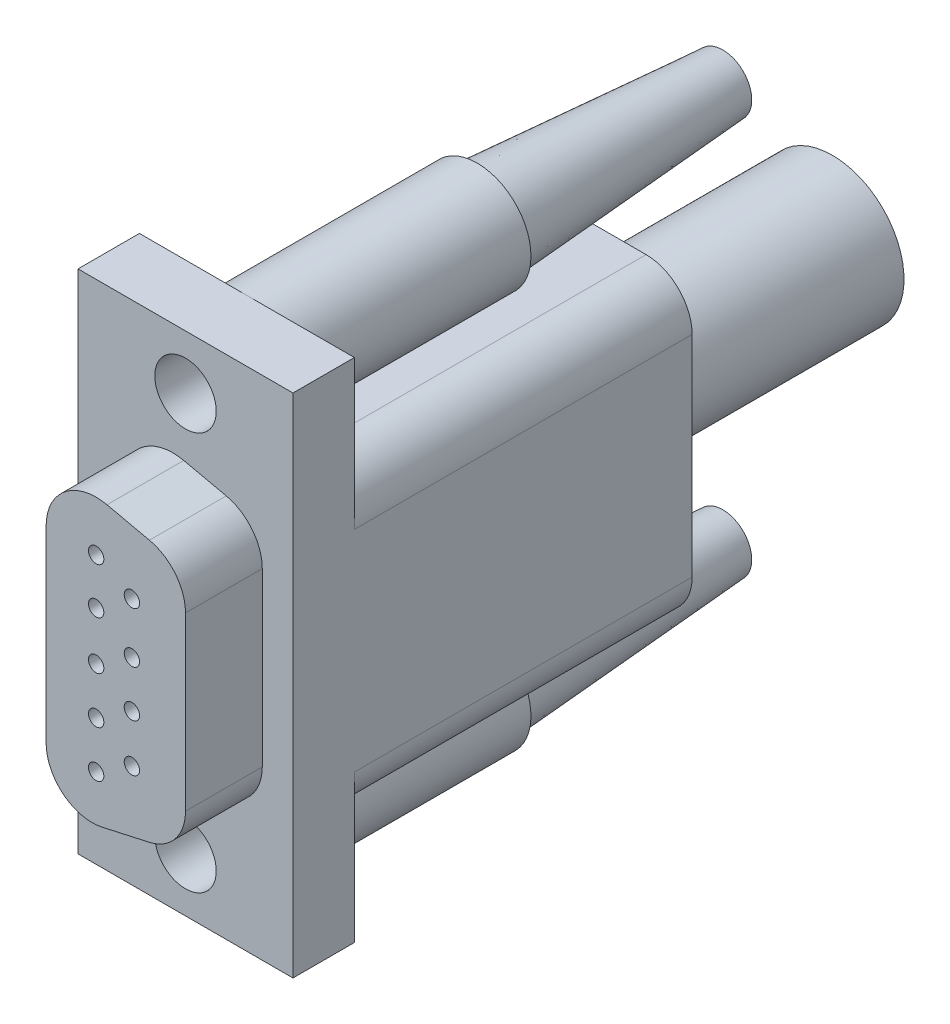
from build123d import *

# Parameters (mm, degrees)
EXTRUDE_1_DEPTH     = 5
SKETCH_2_5_R        = 0.5
CUT_EXTRUDE_1_DEPTH = 6
EXTRUDE_2_DEPTH     = 4
SKETCH_2_8_R        = 2
CUT_EXTRUDE_2_DEPTH = 4
SKETCH_3_R          = 3.5
EXTRUDE_3_DEPTH     = 15
EXTRUDE_4_DEPTH     = 22
SKETCH_5_R          = 3
EXTRUDE_5_DEPTH     = 16
EXTRUDE_5_TAPER     = 4
SKETCH_6_R          = 3
EXTRUDE_6_DEPTH     = 16
EXTRUDE_6_TAPER     = 4
SKETCH_7_R          = 4.663684065
EXTRUDE_7_DEPTH     = 16


with BuildPart() as part:
    # 草图2 → 凸台-拉伸1 (new body)
    with BuildSketch(Plane.XY):
        with BuildLine():
            Line((15.641000066, 15.243423767), (15.641000066, 3.009489297))
            ThreePointArc((15.641000066, 3.009489297), (16.763817885, 0.66936386), (19.291791439, 0.080928117))
            Line((19.291791439, 0.080928117), (22.370518946, 0.765089785))
            ThreePointArc((22.370518946, 0.765089785), (24.059853009, 1.816468785), (24.719727573, 3.693650965))
            Line((24.719727573, 3.693650965), (24.719727573, 14.880621327))
            ThreePointArc((24.719727573, 14.880621327), (24.059853009, 16.757803508), (22.370518946, 17.809182508))
            Line((22.370518946, 17.809182508), (19.605498159, 18.423631571))
            ThreePointArc((19.605498159, 18.423631571), (16.860299842, 17.784632476), (15.641000066, 15.243423767))
        make_face()
    extrude(amount=EXTRUDE_1_DEPTH)

    # 草图2<5> → 切除-拉伸1 (cut)
    with BuildSketch(Plane.XY):
        with Locations((18.898785314, 15.243423767)):
            Circle(SKETCH_2_5_R)
        with Locations((18.898785314, 12.243423767)):
            Circle(SKETCH_2_5_R)
        with Locations((18.898785314, 9.096563263)):
            Circle(SKETCH_2_5_R)
        with Locations((18.898785314, 6.048083228)):
            Circle(SKETCH_2_5_R)
        with Locations((18.898785314, 3.009489297)):
            Circle(SKETCH_2_5_R)
        with Locations((21.228436708, 13.929259558)):
            Circle(SKETCH_2_5_R)
        with Locations((21.228436708, 10.621115871)):
            Circle(SKETCH_2_5_R)
        with Locations((21.228436708, 7.588650825)):
            Circle(SKETCH_2_5_R)
        with Locations((21.228436708, 4.494923859)):
            Circle(SKETCH_2_5_R)
    extrude(amount=CUT_EXTRUDE_1_DEPTH, mode=Mode.SUBTRACT)

    # 草图2<6> → 凸台-拉伸2 (add)
    with BuildSketch(Plane.XY):
        Polygon((12.719727573, 9.287136146), (12.719727573, 25.787136146), (26.719727573, 25.787136146), (26.719727573, -7.212863854), (12.719727573, -7.212863854), align=None)
    extrude(amount=-EXTRUDE_2_DEPTH)

    # 草图2<8> → 切除-拉伸2 (cut)
    with BuildSketch(Plane.XY):
        with Locations((19.719727573, -3.681329619)):
            Circle(SKETCH_2_8_R)
        with Locations((19.719727573, 22.255849174)):
            Circle(SKETCH_2_8_R)
    extrude(amount=-CUT_EXTRUDE_2_DEPTH, mode=Mode.SUBTRACT)

    # 草图3 → 凸台-拉伸3 (add)
    with BuildSketch(Plane(origin=(0, 0, -4), x_dir=(-1, 0, 0), z_dir=(0, 0, -1))):
        with Locations((-19.719727573, 22.255849174)):
            Circle(SKETCH_3_R)
        with Locations((-19.719727573, -3.681329619)):
            Circle(SKETCH_3_R)
    extrude(amount=EXTRUDE_3_DEPTH)

    # 草图4 → 凸台-拉伸4 (add)
    with BuildSketch(Plane(origin=(0, 0, -4), x_dir=(-1, 0, 0), z_dir=(0, 0, -1))):
        with BuildLine():
            Line((-23.719727573, 19.091579688), (-15.719727573, 19.091579688))
            ThreePointArc((-15.719727573, 19.091579688), (-13.598407229, 18.212900031), (-12.719727573, 16.091579688))
            Line((-12.719727573, 16.091579688), (-12.719727573, 2.402820502))
            ThreePointArc((-12.719727573, 2.402820502), (-13.598407229, 0.281500159), (-15.719727573, -0.597179498))
            Line((-15.719727573, -0.597179498), (-23.719727573, -0.597179498))
            ThreePointArc((-23.719727573, -0.597179498), (-25.841047916, 0.281500159), (-26.719727573, 2.402820502))
            Line((-26.719727573, 2.402820502), (-26.719727573, 16.091579688))
            ThreePointArc((-26.719727573, 16.091579688), (-25.841047916, 18.212900031), (-23.719727573, 19.091579688))
        make_face()
    extrude(amount=EXTRUDE_4_DEPTH)

    # 草图5 → 凸台-拉伸5 (add)
    with BuildSketch(Plane(origin=(0, 0, -19), x_dir=(-1, 0, 0), z_dir=(0, 0, -1))):
        with Locations((-19.719727573, 22.255849174)):
            Circle(SKETCH_5_R)
    extrude(amount=EXTRUDE_5_DEPTH, taper=EXTRUDE_5_TAPER)

    # 草图6 → 凸台-拉伸6 (add)
    with BuildSketch(Plane(origin=(0, 0, -19), x_dir=(-1, 0, 0), z_dir=(0, 0, -1))):
        with Locations((-19.719727573, -3.681329619)):
            Circle(SKETCH_6_R)
    extrude(amount=EXTRUDE_6_DEPTH, taper=EXTRUDE_6_TAPER)

    # 草图7 → 凸台-拉伸7 (add)
    with BuildSketch(Plane(origin=(0, 0, -26), x_dir=(-1, 0, 0), z_dir=(0, 0, -1))):
        with Locations((-19.855274078, 10.100415179)):
            Circle(SKETCH_7_R)
    extrude(amount=EXTRUDE_7_DEPTH)


solid = part.part
